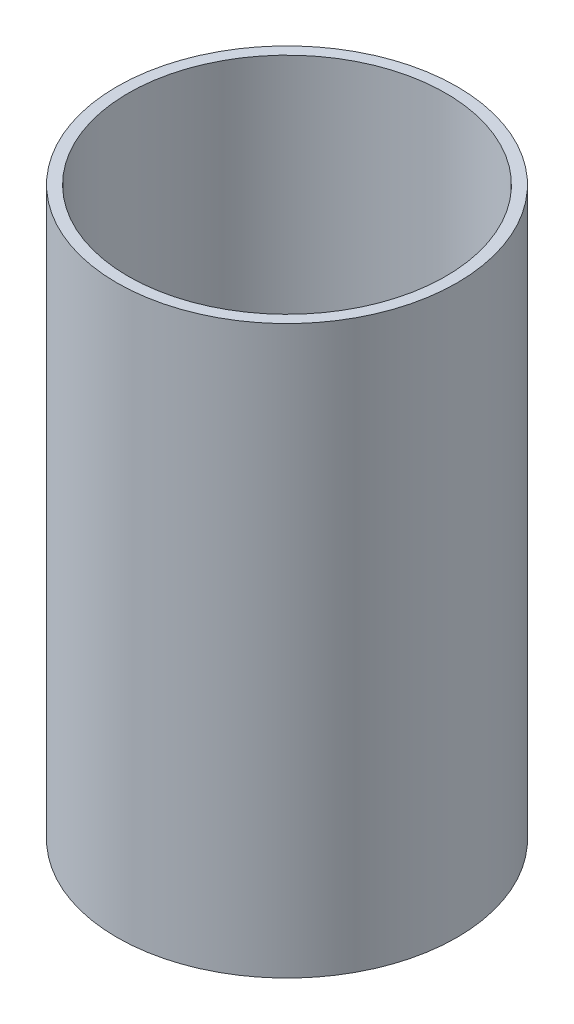
from build123d import *

# Parameters (mm, degrees)
SKETCH1_R           = 30
BOSS_EXTRUDE1_DEPTH = 100
SHELL1_T            = -2


with BuildPart() as part:
    # Sketch1 → Boss-Extrude1 (new body)
    with BuildSketch(Plane(origin=(0, 0, 0), x_dir=(1, 0, 0), z_dir=(0, 1, 0))):
        with Locations(Location((0, 0, 0), (0, 0, 270))):
            Circle(SKETCH1_R)
    extrude(amount=BOSS_EXTRUDE1_DEPTH)

    # Shell1
    shell1_openings = [part.faces().sort_by_distance(p)[0] for p in [
        (0, 100, 0),
    ]]
    offset(amount=SHELL1_T, openings=shell1_openings, kind=Kind.INTERSECTION)


solid = part.part
